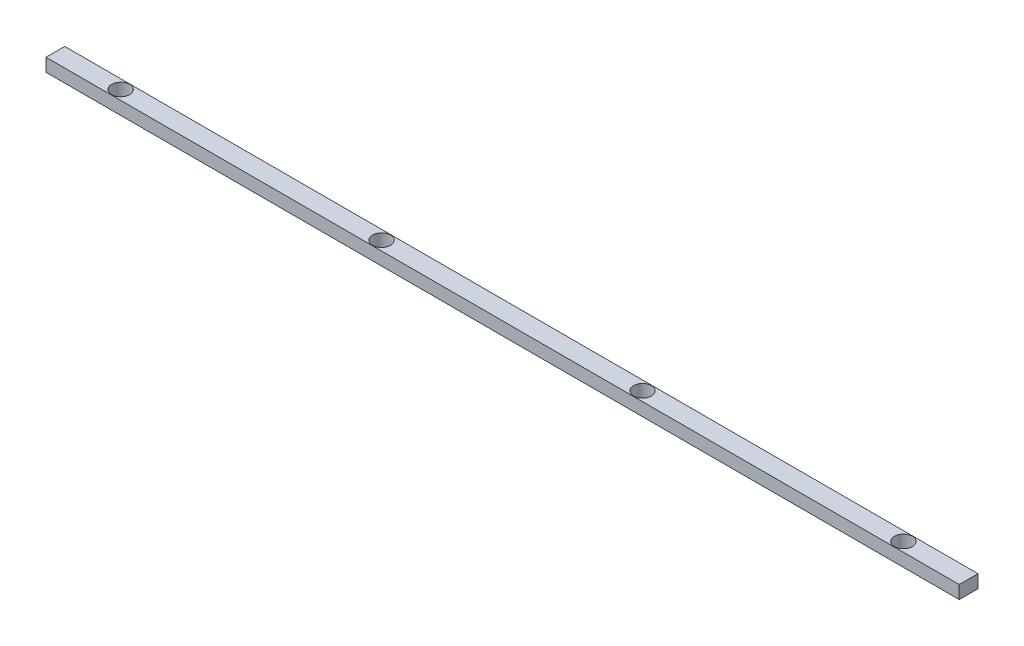
from build123d import *

# Parameters (mm, degrees)
SKETCH1_W           = 355.6
SKETCH1_H           = 7.3025
BOSS_EXTRUDE1_DEPTH = 5.08
SKETCH2_R           = 3.4925
CUT_EXTRUDE1_DEPTH  = 6.08


with BuildPart() as part:
    # Sketch1 → Boss-Extrude1 (new body)
    with BuildSketch(Plane(origin=(0, 0, 0), x_dir=(1, 0, 0), z_dir=(0, 1, 0))):
        Rectangle(SKETCH1_W, SKETCH1_H)
    extrude(amount=BOSS_EXTRUDE1_DEPTH)

    # Sketch2 → Cut-Extrude1 (cut, through all)
    with BuildSketch(Plane(origin=(0, 5.08, 0), x_dir=(1, 0, 0), z_dir=(0, 1, 0))):
        with Locations((-152.4, 0)):
            Circle(SKETCH2_R)
        with Locations((-50.8, 0)):
            Circle(SKETCH2_R)
        with Locations((50.8, 0)):
            Circle(SKETCH2_R)
        with Locations((152.4, 0)):
            Circle(SKETCH2_R)
    extrude(amount=-CUT_EXTRUDE1_DEPTH, mode=Mode.SUBTRACT)


solid = part.part
